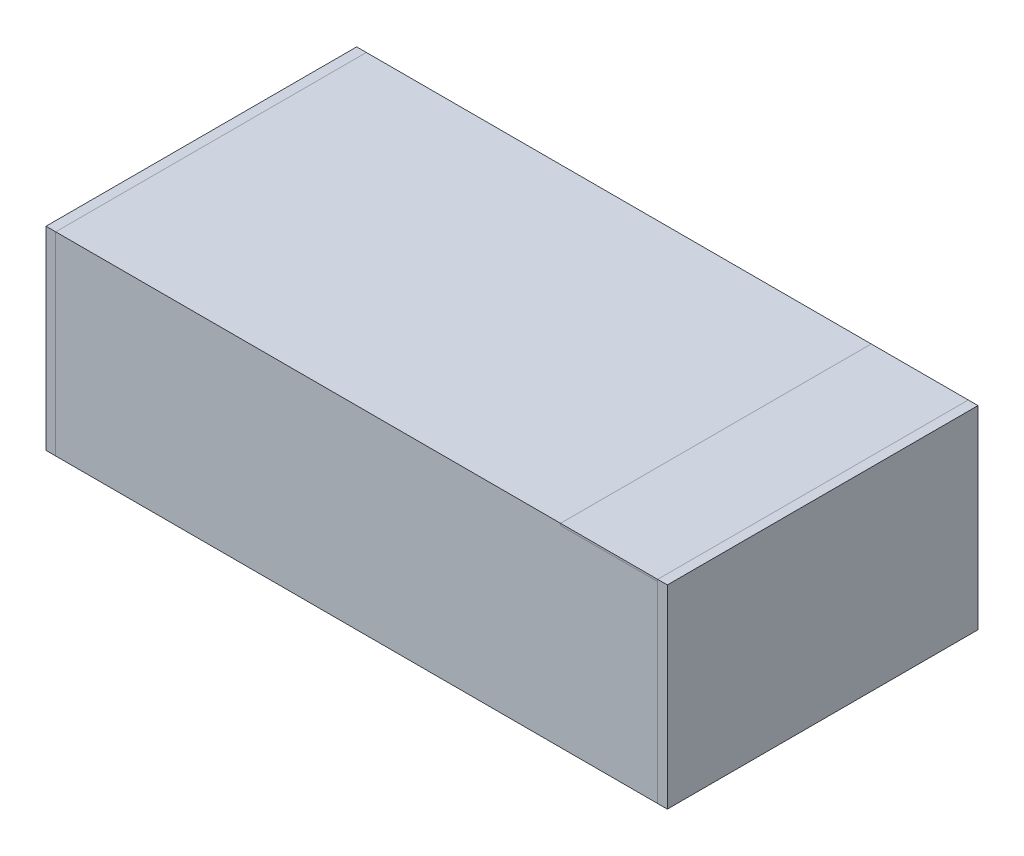
from build123d import *

# Parameters (mm, degrees)
SKETCH1_W             = 3.2
SKETCH1_H             = 1.6
BOSS_EXTRUDE1_DEPTH   = 1
CUT_EXTRUDE2_DEPTH    = 0.05
BOSS_EXTRUDE2_DEPTH   = 0.05
BOSS_EXTRUDE2_2_DEPTH = 0.05
CUT_EXTRUDE3_START    = 1.6
SKETCH3_W             = 1.6
SKETCH3_H             = 0.95
CUT_EXTRUDE3_DEPTH    = 0.05
BOSS_EXTRUDE3_START   = 1.55
SKETCH3_2_W           = 1.6
SKETCH3_2_H           = 0.95
BOSS_EXTRUDE3_DEPTH   = 0.05
CUT_EXTRUDE4_START    = -1.6
SKETCH3_3_W           = 1.6
SKETCH3_3_H           = 0.95
CUT_EXTRUDE4_DEPTH    = 0.05
BOSS_EXTRUDE4_START   = -1.6
SKETCH3_4_W           = 1.6
SKETCH3_4_H           = 0.95
BOSS_EXTRUDE4_DEPTH   = 0.05
CUT_EXTRUDE5_START    = 1
SKETCH5_W             = 0.5
SKETCH5_H             = 1.6
CUT_EXTRUDE5_DEPTH    = 0.01
BOSS_EXTRUDE5_START   = 0.99
SKETCH5_2_W           = 0.5
SKETCH5_2_H           = 1.6
BOSS_EXTRUDE5_DEPTH   = 0.01


with BuildPart() as part:
    # Sketch1 → Boss-Extrude1 (new body)
    with BuildSketch(Plane(origin=(0, 0, 0), x_dir=(1, 0, 0), z_dir=(0, 1, 0))):
        Rectangle(SKETCH1_W, SKETCH1_H)
    extrude(amount=BOSS_EXTRUDE1_DEPTH)

    # Sketch2 → Cut-Extrude2 (cut)
    with BuildSketch(Plane(origin=(0, 0, 0), x_dir=(1, 0, 0), z_dir=(0, 1, 0))):
        Polygon((-0.8, -0.75), (-0.8, 0.75), (-1.4, 0.75), (-1.55, 0.65), (-1.55, 0.8), (-1.6, 0.8), (-1.6, -0.8), (-1.55, -0.8), (-1.55, -0.65), (-1.4, -0.75), align=None)
        Polygon((1.55, 0.65), (1.4, 0.75), (0.8, 0.75), (0.8, -0.75), (1.4, -0.75), (1.55, -0.65), (1.55, -0.8), (1.6, -0.8), (1.6, 0.8), (1.55, 0.8), align=None)
    extrude(amount=CUT_EXTRUDE2_DEPTH, mode=Mode.SUBTRACT)

    # Sketch3 → Cut-Extrude3 (cut)
    with BuildSketch(Plane(origin=(0, 0, 0), x_dir=(0, 0, -1), z_dir=(1, 0, 0)).offset(CUT_EXTRUDE3_START)):
        with Locations((0, 0.525)):
            Rectangle(SKETCH3_W, SKETCH3_H)
    extrude(amount=-CUT_EXTRUDE3_DEPTH, mode=Mode.SUBTRACT)

    # Sketch3_3 → Cut-Extrude4 (cut)
    with BuildSketch(Plane(origin=(0, 0, 0), x_dir=(0, 0, -1), z_dir=(1, 0, 0)).offset(CUT_EXTRUDE4_START)):
        with Locations((0, 0.525)):
            Rectangle(SKETCH3_3_W, SKETCH3_3_H)
    extrude(amount=CUT_EXTRUDE4_DEPTH, mode=Mode.SUBTRACT)

    # Sketch5 → Cut-Extrude5 (cut)
    with BuildSketch(Plane(origin=(0, 0, 0), x_dir=(1, 0, 0), z_dir=(0, 1, 0)).offset(CUT_EXTRUDE5_START)):
        with Locations((1.3, 0)):
            Rectangle(SKETCH5_W, SKETCH5_H)
    extrude(amount=-CUT_EXTRUDE5_DEPTH, mode=Mode.SUBTRACT)


with BuildPart() as body_2:
    # Sketch2_2 → Boss-Extrude2 (new body)
    with BuildSketch(Plane(origin=(0, 0, 0), x_dir=(1, 0, 0), z_dir=(0, 1, 0))):
        Polygon((-0.8, -0.75), (-0.8, 0.75), (-1.4, 0.75), (-1.55, 0.65), (-1.55, 0.8), (-1.6, 0.8), (-1.6, -0.8), (-1.55, -0.8), (-1.55, -0.65), (-1.4, -0.75), align=None)
    extrude(amount=BOSS_EXTRUDE2_DEPTH)

    # Sketch3_4 → Boss-Extrude4 (add)
    with BuildSketch(Plane(origin=(0, 0, 0), x_dir=(0, 0, -1), z_dir=(1, 0, 0)).offset(BOSS_EXTRUDE4_START)):
        with Locations((0, 0.525)):
            Rectangle(SKETCH3_4_W, SKETCH3_4_H)
    extrude(amount=BOSS_EXTRUDE4_DEPTH)


with BuildPart() as body_3:
    # Sketch2_2 → Boss-Extrude2 2 (new body)
    with BuildSketch(Plane(origin=(0, 0, 0), x_dir=(1, 0, 0), z_dir=(0, 1, 0))):
        Polygon((1.55, 0.65), (1.4, 0.75), (0.8, 0.75), (0.8, -0.75), (1.4, -0.75), (1.55, -0.65), (1.55, -0.8), (1.6, -0.8), (1.6, 0.8), (1.55, 0.8), align=None)
    extrude(amount=BOSS_EXTRUDE2_2_DEPTH)

    # Sketch3_2 → Boss-Extrude3 (add)
    with BuildSketch(Plane(origin=(0, 0, 0), x_dir=(0, 0, -1), z_dir=(1, 0, 0)).offset(BOSS_EXTRUDE3_START)):
        with Locations((0, 0.525)):
            Rectangle(SKETCH3_2_W, SKETCH3_2_H)
    extrude(amount=BOSS_EXTRUDE3_DEPTH)


with BuildPart() as body_4:
    # Sketch5_2 → Boss-Extrude5 (new body)
    with BuildSketch(Plane(origin=(0, 0, 0), x_dir=(1, 0, 0), z_dir=(0, 1, 0)).offset(BOSS_EXTRUDE5_START)):
        with Locations((1.3, 0)):
            Rectangle(SKETCH5_2_W, SKETCH5_2_H)
    extrude(amount=BOSS_EXTRUDE5_DEPTH)


solid = Compound([part.part, body_2.part, body_3.part, body_4.part])
